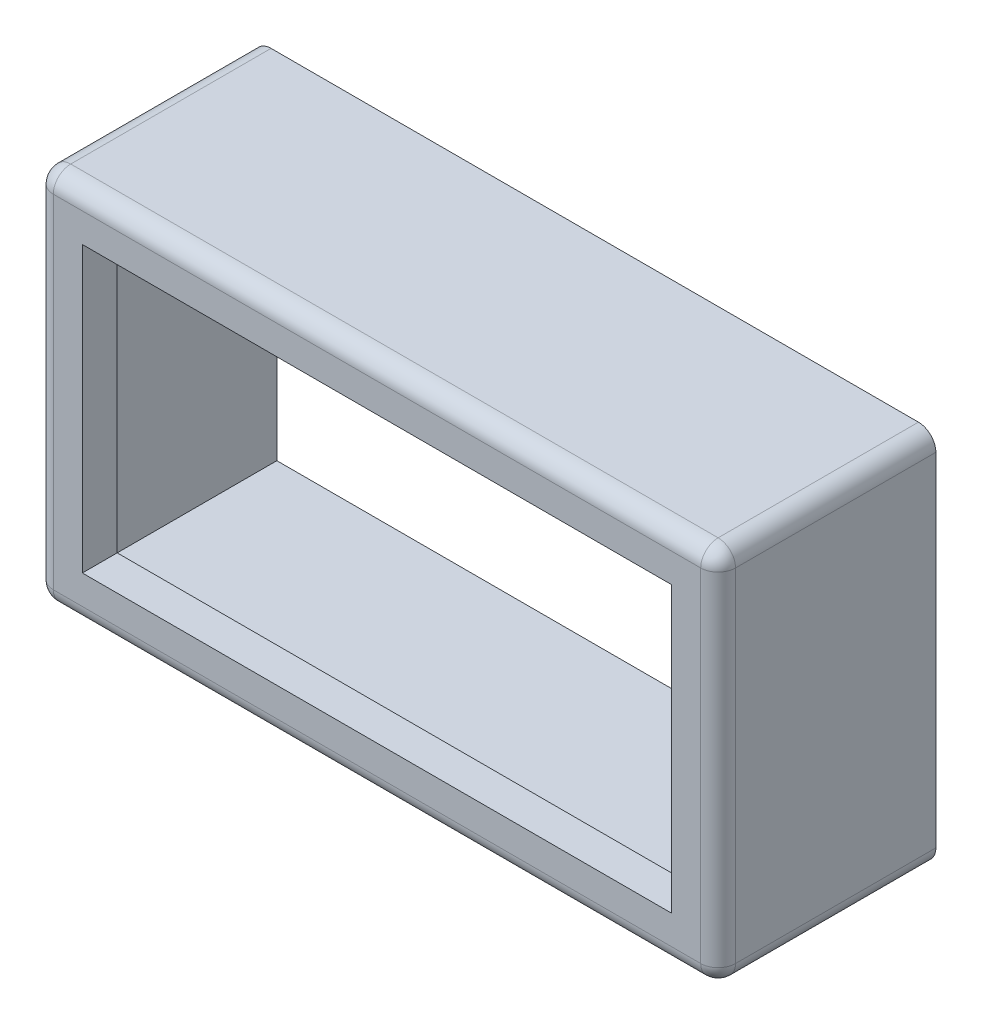
from build123d import *

# Parameters (mm, degrees)
SKETCH1_W           = 14.9225
SKETCH1_H           = 8.255
SKETCH1_W_2         = 12.8905
SKETCH1_H_2         = 6.223
BOSS_EXTRUDE1_DEPTH = 4.7625
SKETCH2_W           = 13.9065
SKETCH2_H           = 7.239
CUT_EXTRUDE1_DEPTH  = 4.0005
FILLET1_R           = 0.381


with BuildPart() as part:
    # Sketch1 → Boss-Extrude1 (new body)
    with BuildSketch(Plane.XY):
        with Locations((22.225, -43.18)):
            Rectangle(SKETCH1_W, SKETCH1_H)
        with Locations((22.225, -43.18)):
            Rectangle(SKETCH1_W_2, SKETCH1_H_2, mode=Mode.SUBTRACT)
    extrude(amount=-BOSS_EXTRUDE1_DEPTH)

    # Sketch2 → Cut-Extrude1 (cut)
    with BuildSketch(Plane(origin=(0, 0, -4.7625), x_dir=(-1, 0, 0), z_dir=(0, 0, -1))):
        with Locations((-22.225, -43.18)):
            Rectangle(SKETCH2_W, SKETCH2_H)
    extrude(amount=-CUT_EXTRUDE1_DEPTH, mode=Mode.SUBTRACT)

    # Fillet1
    fillet1_edges = [part.edges().sort_by_distance(p)[0] for p in [
        (22.225, -47.3075, 0),
        (14.76375, -43.18, 0),
        (22.225, -39.0525, 0),
        (29.68625, -43.18, 0),
        (29.68625, -47.3075, -2.38125),
        (14.76375, -47.3075, -2.38125),
        (14.76375, -39.0525, -2.38125),
        (29.68625, -39.0525, -2.38125),
    ]]
    fillet(fillet1_edges, radius=FILLET1_R)


solid = part.part
